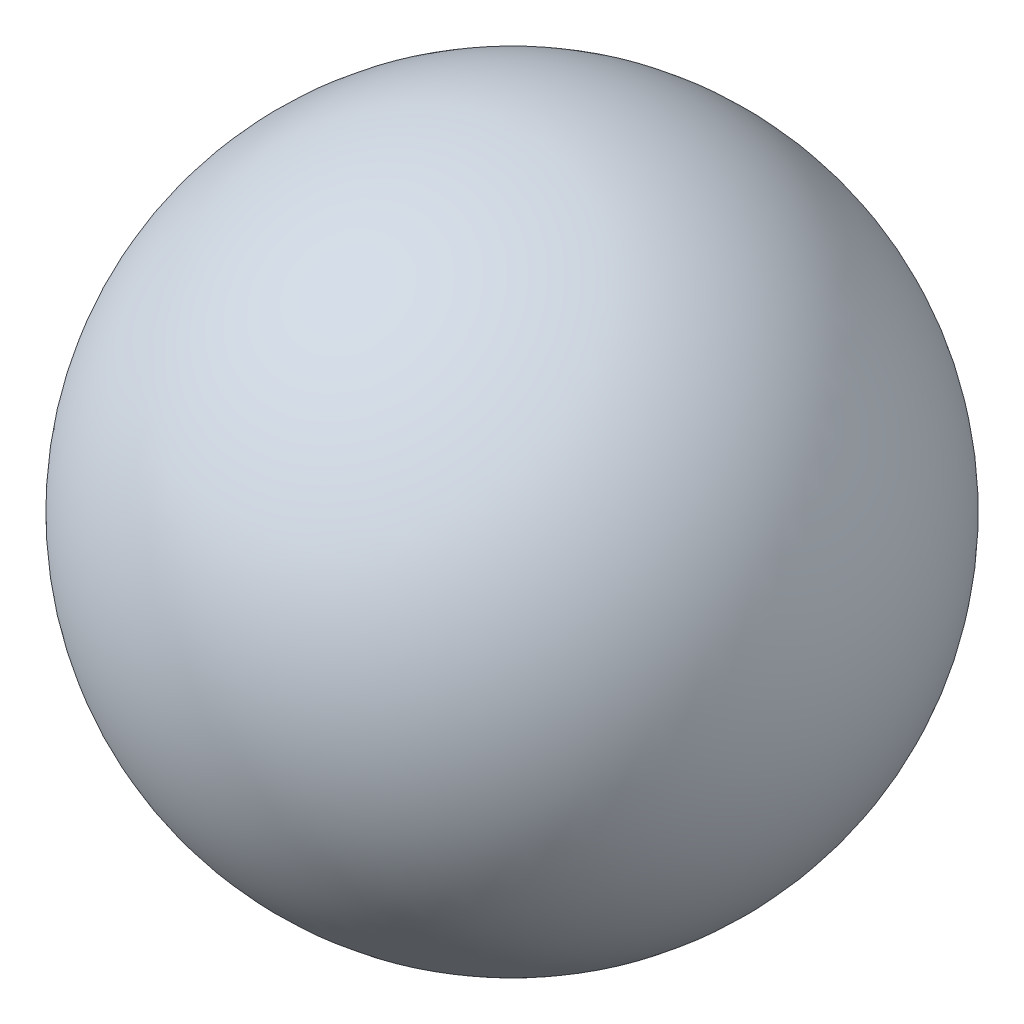
from build123d import *


with BuildPart() as part:
    # Esquisse1 → Révolution1 (revolve)
    with BuildSketch(Plane.XY):
        with BuildLine():
            Line((0, 7.5), (0, -7.5))
            ThreePointArc((0, -7.5), (-7.5, 0), (0, 7.5))
        make_face()
    revolve(axis=Axis((0, 7.5, 0), (0, -1, 0)))


solid = part.part
